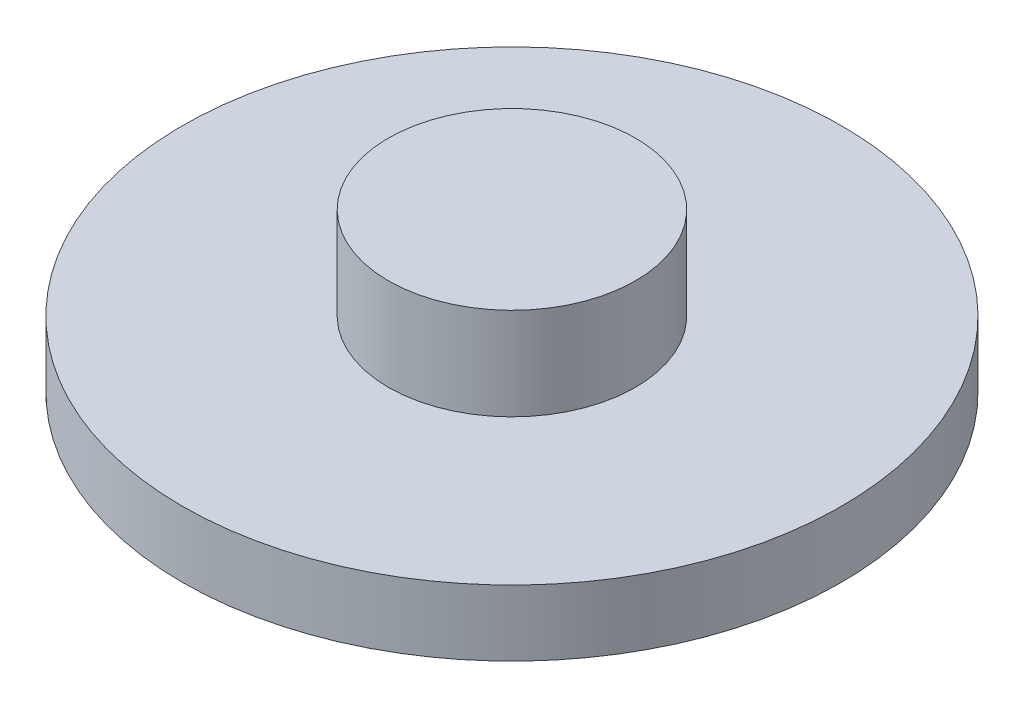
from build123d import *

# Parameters (mm, degrees)
SKETCH1_R           = 25.4
BOSS_EXTRUDE1_DEPTH = 5.08
SKETCH4_R           = 9.525
BOSS_EXTRUDE2_DEPTH = 7.112


with BuildPart() as part:
    # Sketch1 → Boss-Extrude1 (new body)
    with BuildSketch(Plane(origin=(0, 0, 0), x_dir=(1, 0, 0), z_dir=(0, 1, 0))):
        Circle(SKETCH1_R)
    extrude(amount=BOSS_EXTRUDE1_DEPTH)

    # Sketch4 → Boss-Extrude2 (add)
    with BuildSketch(Plane(origin=(0, 5.08, 0), x_dir=(1, 0, 0), z_dir=(0, 1, 0))):
        Circle(SKETCH4_R)
    extrude(amount=BOSS_EXTRUDE2_DEPTH)


solid = part.part
